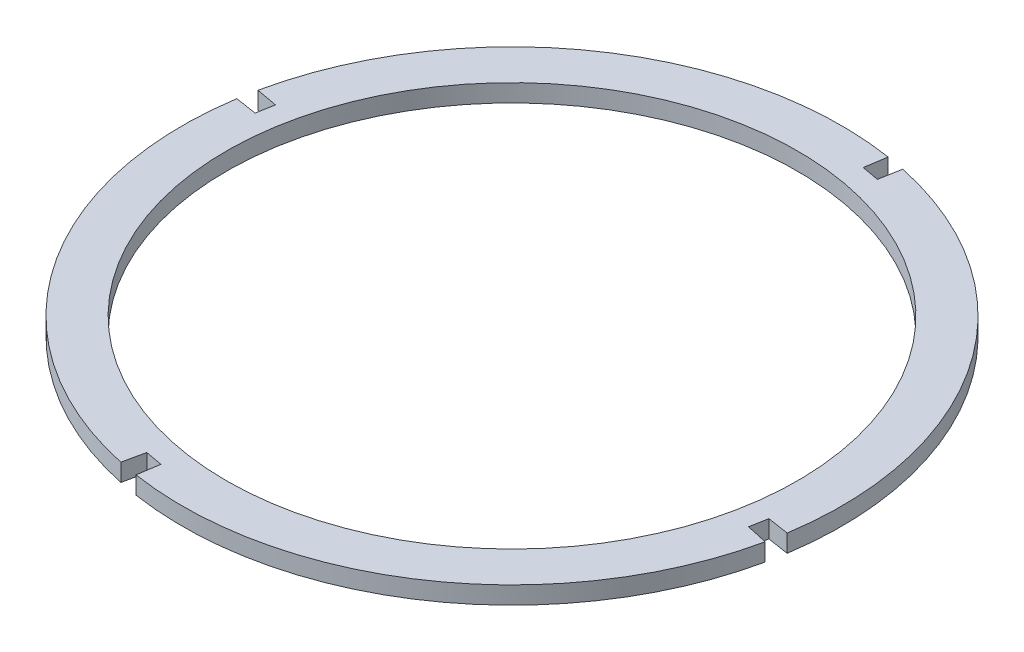
from build123d import *

# Parameters (mm, degrees)
SKETCH_1_R      = 260
EXTRUDE_3_DEPTH = 16


with BuildPart() as part:
    # Эскиз1 → Бобышка-Вытянуть3 (new body)
    with BuildSketch(Plane(origin=(0, 0, 0), x_dir=(1, 0, 0), z_dir=(0, 1, 0))):
        with BuildLine():
            Line((-564.131109826, 487.398330281), (-548.396606244, 484.495676837))
            Line((-548.396606244, 484.495676837), (-544.787643902, 504.058890969))
            ThreePointArc((-544.787643902, 504.058890969), (-360.125373537, 380.954998191), (-310.604335978, 164.61639934))
            Line((-310.604335978, 164.61639934), (-330.255153903, 167.66400738))
            Line((-330.255153903, 167.66400738), (-333.157807348, 151.929503798))
            Line((-333.157807348, 151.929503798), (-313.713053206, 147.764879413))
            ThreePointArc((-313.713053206, 147.764879413), (-436.861002003, -36.453770733), (-652.865766443, -85.889285226))
            Line((-652.865766443, -85.889285226), (-649.829869088, -66.239005386))
            Line((-649.829869088, -66.239005386), (-665.565211025, -63.340900125))
            Line((-665.565211025, -63.340900125), (-669.719078569, -82.790306674))
            ThreePointArc((-669.719078569, -82.790306674), (-854.107254512, 40.393898968), (-903.516250652, 256.569982398))
            Line((-903.516250652, 256.569982398), (-883.865432727, 253.522374358))
            Line((-883.865432727, 253.522374358), (-880.962779283, 269.256877941))
            Line((-880.962779283, 269.256877941), (-900.525993415, 272.865840282))
            ThreePointArc((-900.525993415, 272.865840282), (-777.422100637, 457.528110648), (-561.083501786, 507.049148206))
            Line((-561.083501786, 507.049148206), (-564.131109826, 487.398330281))
        make_face()
        with Locations((-607.060293315, 210.593190869)):
            Circle(SKETCH_1_R, mode=Mode.SUBTRACT)
    extrude(amount=EXTRUDE_3_DEPTH)


solid = part.part
